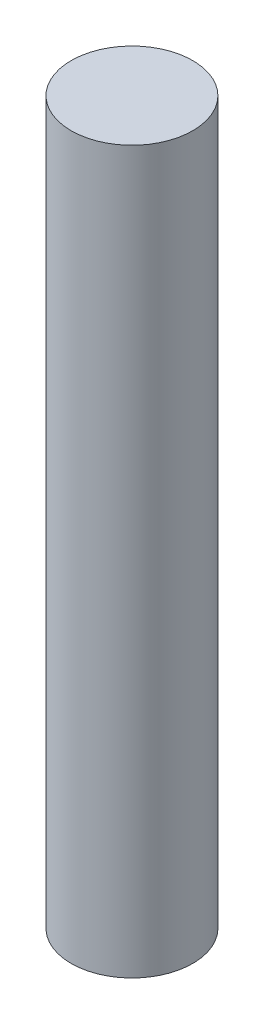
from build123d import *

# Parameters (mm, degrees)
SKETCH1_R      = 77
SKETCH1_R_2    = 72
EXTRUDE1_DEPTH = 454.2
SKETCH2_R      = 77
EXTRUDE2_DEPTH = 5


with BuildPart() as part:
    # Sketch1 → Extrude1 (new body, symmetric)
    with BuildSketch(Plane(origin=(0, 0, 0), x_dir=(1, 0, 0), z_dir=(0, 1, 0))):
        with Locations(Location((0, 0, 0), (0, 0, 270))):  # turned: the seam where the file's is
            Circle(SKETCH1_R)
        with Locations(Location((0, 0, 0), (0, 0, 270))):  # turned: the seam where the file's is
            Circle(SKETCH1_R_2, mode=Mode.SUBTRACT)
    extrude(amount=EXTRUDE1_DEPTH, both=True)

    # Sketch2 → Extrude2 (add)
    with BuildSketch(Plane(origin=(0, 454.2, 0), x_dir=(1, 0, 0), z_dir=(0, 1, 0))):
        with Locations(Location((0, 0, 0), (0, 0, 270))):  # turned: the seam where the file's is
            Circle(SKETCH2_R)
    extrude(amount=EXTRUDE2_DEPTH)


solid = part.part
